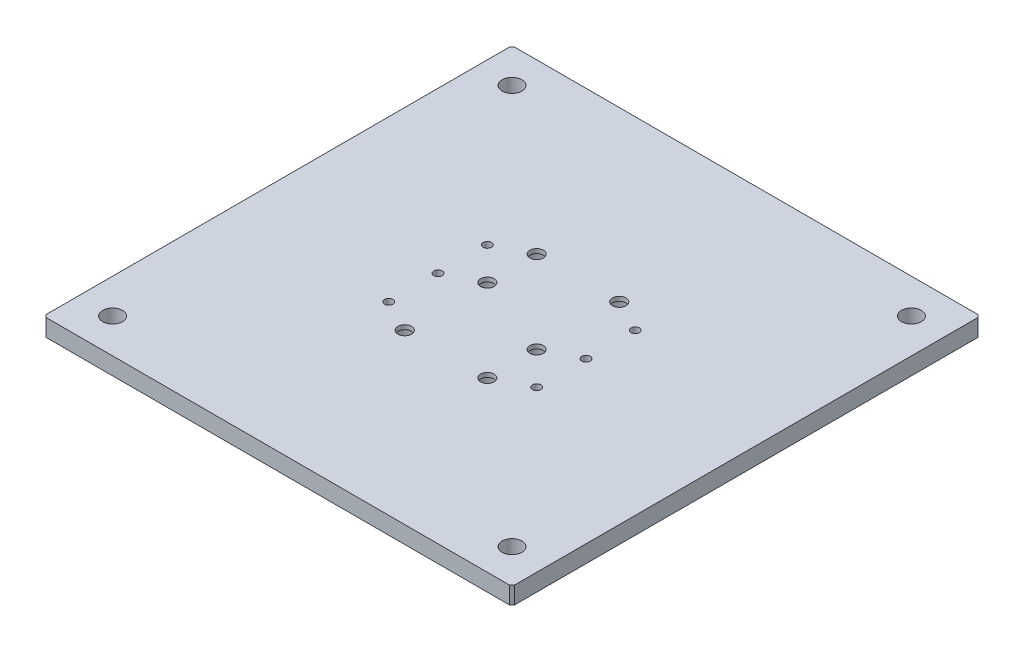
from build123d import *

# Parameters (mm, degrees)
SKETCH_1_W                    = 380
SKETCH_1_H                    = 380
EXTRUDE_1_DEPTH               = 14
CHAMFER_1_SIZE                = 2
HOLE_WIZARD_M8_1_D            = 6.8
HOLE_WIZARD_M10_1_D           = 11
HOLE_WIZARD_M10_1_CBORE_D     = 22
HOLE_WIZARD_M10_1_CBORE_DEPTH = 10.5
SKETCH_6_R                    = 8
CUT_EXTRUDE_1_DEPTH           = 15


with BuildPart() as part:
    # 草图1 → 凸台-拉伸1 (new body)
    with BuildSketch(Plane(origin=(0, 0, 0), x_dir=(1, 0, 0), z_dir=(0, 1, 0))):
        Rectangle(SKETCH_1_W, SKETCH_1_H)
    extrude(amount=EXTRUDE_1_DEPTH)

    # 倒角1
    chamfer_1_edges = [part.edges().sort_by_distance(p)[0] for p in [
        (-190, 7, -190),
        (190, 7, -190),
        (190, 7, 190),
        (-190, 7, 190),
    ]]
    chamfer(chamfer_1_edges, length=CHAMFER_1_SIZE)

    # M8 螺纹孔的螺纹孔钻头1 (through all)
    with Locations(Plane(origin=(0, 14, 0), x_dir=(1, 0, 0), z_dir=(0, 1, 0))):
        with Locations((60, 40), (60, 0), (60, -40)):
            hole_wizard_m8_1 = Hole(HOLE_WIZARD_M8_1_D / 2)

    # 镜向1: M8 螺纹孔的螺纹孔钻头1 across plane
    add(hole_wizard_m8_1.mirror(Plane(origin=(0, 0, 0), x_dir=(0, 0, 1), z_dir=(1, 0, 0))), mode=Mode.SUBTRACT)

    # M10 六角头螺栓的柱形沉头孔1 (through all)
    with Locations(Plane(origin=(0, 0, 0), x_dir=(-1, 0, 0), z_dir=(0, -1, 0))):
        with Locations((33.5, 53.5), (-33.5, -13.5), (33.5, -53.5), (-33.5, 53.5), (-33.5, -53.5), (33.5, 13.5)):
            CounterBoreHole(HOLE_WIZARD_M10_1_D / 2, HOLE_WIZARD_M10_1_CBORE_D / 2, HOLE_WIZARD_M10_1_CBORE_DEPTH)

    # 草图6 → 切除-拉伸1 (cut, through all)
    with BuildSketch(Plane(origin=(0, 14, 0), x_dir=(1, 0, 0), z_dir=(0, 1, 0))):
        with Locations((-162, 162)):
            Circle(SKETCH_6_R)
        with Locations((162, 162)):
            Circle(SKETCH_6_R)
        with Locations((-162, -162)):
            Circle(SKETCH_6_R)
        with Locations((162, -162)):
            Circle(SKETCH_6_R)
    extrude(amount=-CUT_EXTRUDE_1_DEPTH, mode=Mode.SUBTRACT)


solid = part.part
